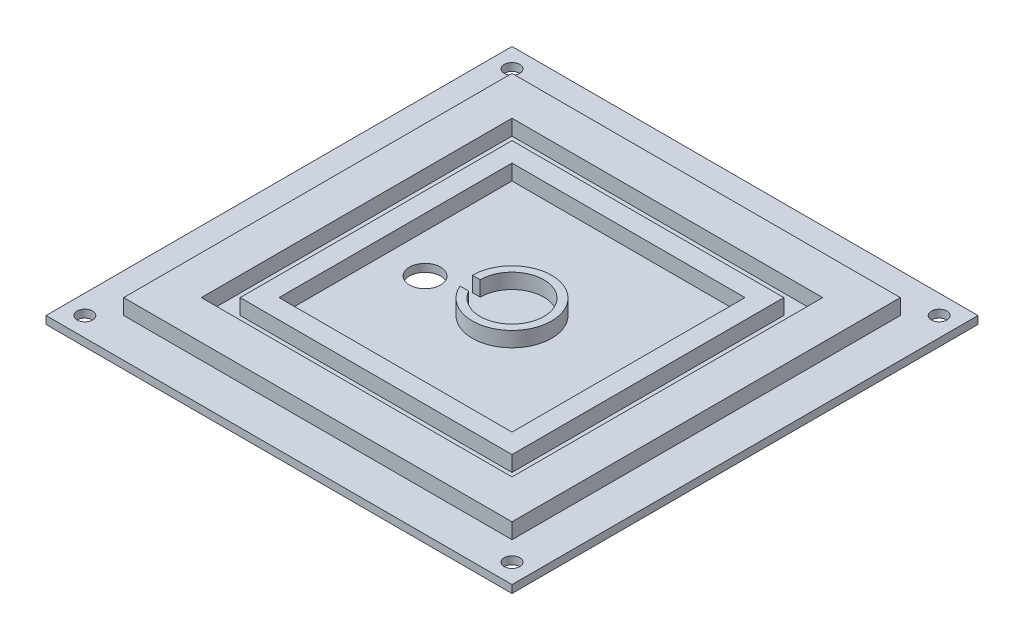
from build123d import *

# Parameters (mm, degrees)
SKETCH1_W           = 152.4
SKETCH1_H           = 152.4
BOSS_EXTRUDE1_DEPTH = 2.54
SKETCH2_W           = 127
SKETCH2_H           = 127
BOSS_EXTRUDE3_DEPTH = 5.08
SKETCH3_W           = 101.6
SKETCH3_H           = 101.6
CUT_EXTRUDE2_DEPTH  = 5.08
SKETCH5_W           = 88.9
SKETCH5_H           = 88.9
BOSS_EXTRUDE4_DEPTH = 5.08
SKETCH6_W           = 76.2
SKETCH6_H           = 76.2
CUT_EXTRUDE3_DEPTH  = 5.08
BOSS_EXTRUDE5_DEPTH = 2.794
SKETCH8_R           = 5.08
CUT_EXTRUDE4_DEPTH  = 108.882743755
SKETCH9_R           = 2.54
CUT_EXTRUDE5_DEPTH  = 108.882743755
BOSS_EXTRUDE6_DEPTH = 4.9276


with BuildPart() as part:
    # Sketch1 → Boss-Extrude1 (new body)
    with BuildSketch(Plane(origin=(0, 0, 0), x_dir=(1, 0, 0), z_dir=(0, 1, 0))):
        Rectangle(SKETCH1_W, SKETCH1_H)
    extrude(amount=-BOSS_EXTRUDE1_DEPTH)

    # Sketch2 → Boss-Extrude3 (add)
    with BuildSketch(Plane(origin=(0, 0, 0), x_dir=(1, 0, 0), z_dir=(0, 1, 0))):
        Rectangle(SKETCH2_W, SKETCH2_H)
    extrude(amount=BOSS_EXTRUDE3_DEPTH)

    # Sketch3 → Cut-Extrude2 (cut)
    with BuildSketch(Plane(origin=(0, 5.08, 0), x_dir=(1, 0, 0), z_dir=(0, 1, 0))):
        Rectangle(SKETCH3_W, SKETCH3_H)
    extrude(amount=-CUT_EXTRUDE2_DEPTH, mode=Mode.SUBTRACT)

    # Sketch5 → Boss-Extrude4 (add)
    with BuildSketch(Plane(origin=(0, 0, 0), x_dir=(1, 0, 0), z_dir=(0, 1, 0))):
        Rectangle(SKETCH5_W, SKETCH5_H)
    extrude(amount=BOSS_EXTRUDE4_DEPTH)

    # Sketch6 → Cut-Extrude3 (cut)
    with BuildSketch(Plane(origin=(0, 5.08, 0), x_dir=(1, 0, 0), z_dir=(0, 1, 0))):
        Rectangle(SKETCH6_W, SKETCH6_H)
    extrude(amount=-CUT_EXTRUDE3_DEPTH, mode=Mode.SUBTRACT)

    # Sketch7 → Boss-Extrude5 (add)
    with BuildSketch(Plane(origin=(0, 0, 0), x_dir=(1, 0, 0), z_dir=(0, 1, 0))):
        with BuildLine():
            Line((-10.414, 0), (-12.954, 0))
            ThreePointArc((-12.954, 0), (12.691940102, 2.592445263), (-11.916363371, -5.08))
            Line((-11.916363371, -5.08), (-9.090929325, -5.08))
            ThreePointArc((-9.090929325, -5.08), (10.077805664, 2.624734082), (-10.414, 0))
        make_face()
    extrude(amount=BOSS_EXTRUDE5_DEPTH)

    # Sketch8 → Cut-Extrude4 (cut, through all)
    with BuildSketch(Plane(origin=(0, 0, 0), x_dir=(1, 0, 0), z_dir=(0, 1, 0))):
        with Locations((-25.4, -3.048)):
            Circle(SKETCH8_R)
    extrude(amount=-CUT_EXTRUDE4_DEPTH, mode=Mode.SUBTRACT)

    # Sketch9 → Cut-Extrude5 (cut, through all)
    with BuildSketch(Plane(origin=(0, 0, 0), x_dir=(1, 0, 0), z_dir=(0, 1, 0))):
        with Locations((-69.85, -69.85)):
            Circle(SKETCH9_R)
        with Locations((69.85, -69.85)):
            Circle(SKETCH9_R)
        with Locations((69.85, 69.85)):
            Circle(SKETCH9_R)
        with Locations((-69.85, 69.85)):
            Circle(SKETCH9_R)
    extrude(amount=-CUT_EXTRUDE5_DEPTH, mode=Mode.SUBTRACT)

    # Sketch7_2 → Boss-Extrude6 (add)
    with BuildSketch(Plane(origin=(0, 0, 0), x_dir=(1, 0, 0), z_dir=(0, 1, 0))):
        with BuildLine():
            Line((-10.414, 0), (-12.954, 0))
            ThreePointArc((-12.954, 0), (12.691940102, 2.592445263), (-11.916363371, -5.08))
            Line((-11.916363371, -5.08), (-9.090929325, -5.08))
            ThreePointArc((-9.090929325, -5.08), (10.077805664, 2.624734082), (-10.414, 0))
        make_face()
    extrude(amount=BOSS_EXTRUDE6_DEPTH)


solid = part.part
